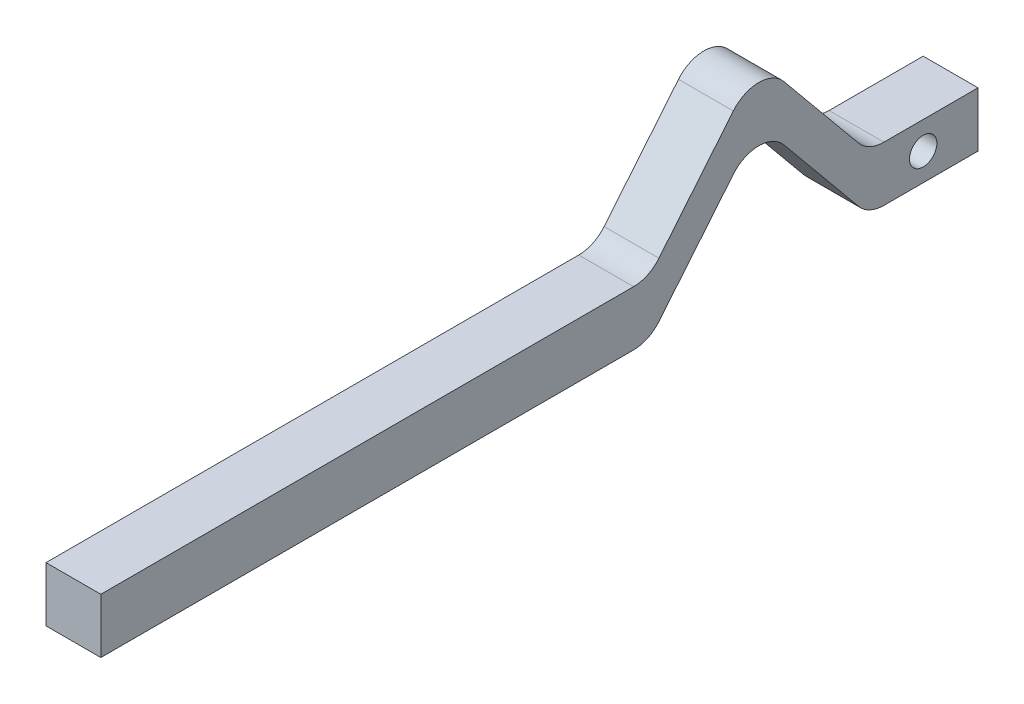
from build123d import *

# Parameters (mm, degrees)
SKETCH3_W           = 25.4
SKETCH3_H           = 12.7
SKETCH3_W_2         = 127
BOSS_EXTRUDE1_DEPTH = 6.35
FILLET1_R           = 7.62
SKETCH5_R           = 3.175
CUT_EXTRUDE2_DEPTH  = 13.7


with BuildPart() as part:
    # Sketch3 → Boss-Extrude1 (new body, symmetric)
    with BuildSketch(Plane(origin=(0, 0, 0), x_dir=(0, 0, -1), z_dir=(1, 0, 0))):
        with Locations((88.9, 0)):
            Rectangle(SKETCH3_W, SKETCH3_H)
        Polygon((76.2, 6.35), (50.8, 37.177887789), (50.8, 24.477887789), (65.736097893, 6.35), align=None)
        Polygon((65.736097893, 6.35), (76.2, -6.35), (76.2, 6.35), align=None)
        Polygon((50.8, 37.177887789), (25.4, 6.35), (35.863902107, 6.35), (50.8, 24.477887789), align=None)
        Polygon((35.863902107, 6.35), (25.4, 6.35), (25.4, -6.35), align=None)
        with Locations((-38.1, 0)):
            Rectangle(SKETCH3_W_2, SKETCH3_H)
    extrude(amount=BOSS_EXTRUDE1_DEPTH, both=True)

    # Fillet1
    fillet1_edges = [part.edges().sort_by_distance(p)[0] for p in [
        (0, -6.35, -76.2),
        (0, 24.477887789, -50.8),
        (0, -6.35, -25.4),
        (0, 6.35, -25.4),
        (0, 37.177887789, -50.8),
        (0, 6.35, -76.2),
    ]]
    fillet(fillet1_edges, radius=FILLET1_R)

    # Sketch5 → Cut-Extrude2 (cut, through all)
    with BuildSketch(Plane(origin=(6.35, 0, 0), x_dir=(0, 0, -1), z_dir=(1, 0, 0))):
        with Locations((88.9, 0)):
            Circle(SKETCH5_R)
    extrude(amount=-CUT_EXTRUDE2_DEPTH, mode=Mode.SUBTRACT)


solid = part.part
